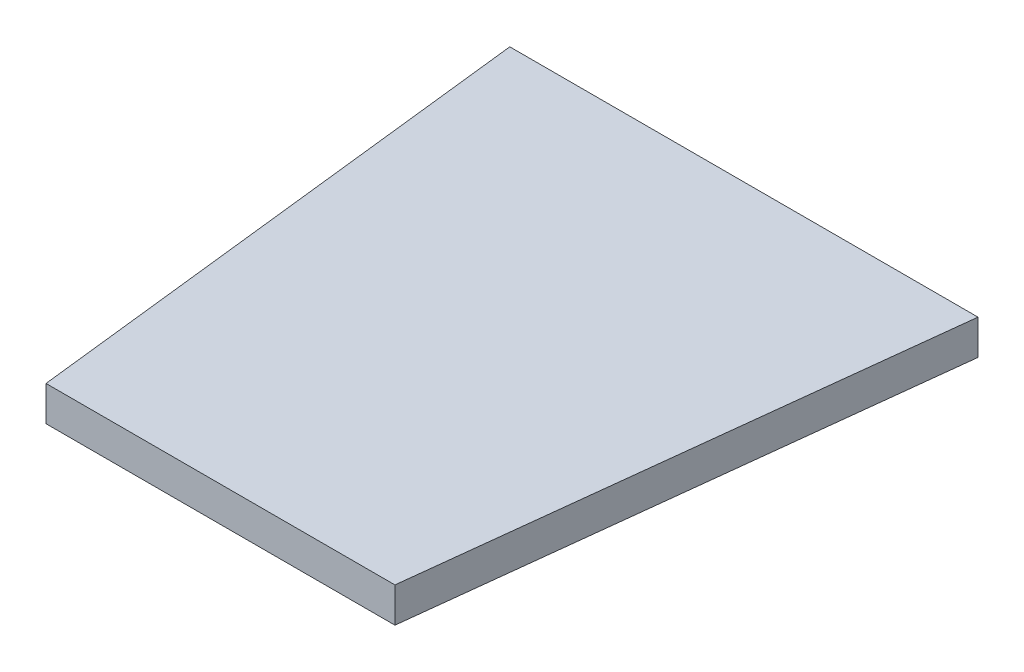
from build123d import *

# Parameters (mm, degrees)
BOSS_EXTRUDE1_DEPTH = 3


with BuildPart() as part:
    # Sketch1 → Boss-Extrude1 (new body)
    with BuildSketch(Plane(origin=(0, 0, 0), x_dir=(1, 0, 0), z_dir=(0, 1, 0))):
        Polygon((-20.127102374, 99.5), (-15, 54.5), (0, 54.5), (0, 99.5), align=None)
    boss_extrude1 = extrude(amount=BOSS_EXTRUDE1_DEPTH)

    # Mirror2: Boss-Extrude1 across plane
    add(boss_extrude1.mirror(Plane(origin=(0, 0, 0), x_dir=(0, 0, 1), z_dir=(1, 0, 0))))


solid = part.part
